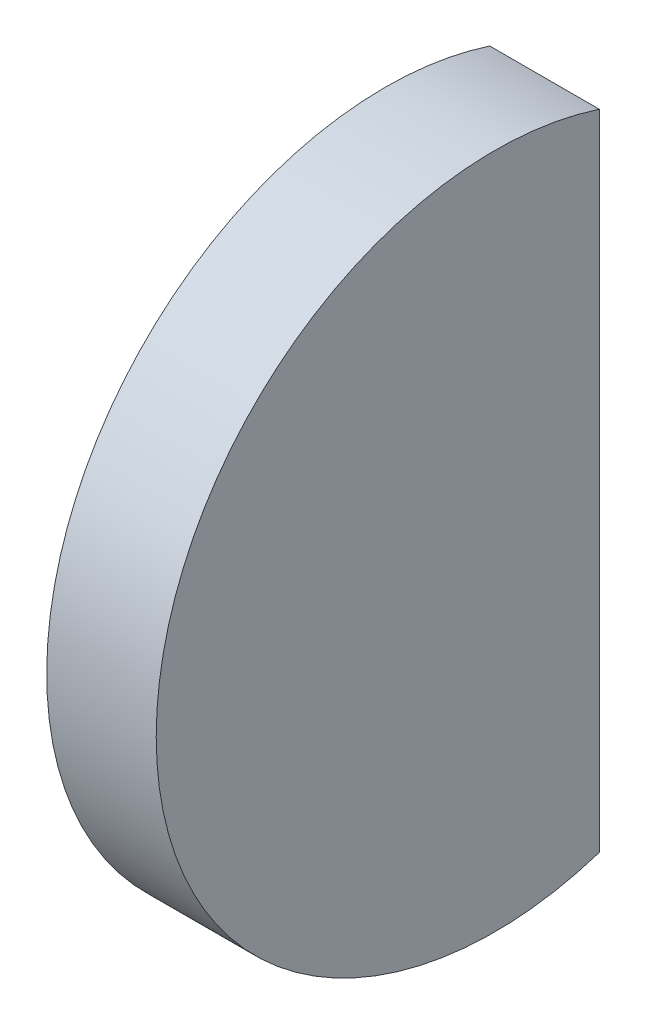
from build123d import *

# Parameters (mm, degrees)
CUT_EXTRUDE_1_DEPTH = 6.5


with BuildPart() as part:
    # Эскиз1 → Повернуть1 (revolve)
    with BuildSketch(Plane.XY):
        with BuildLine():
            Line((1.941000017, 11), (5.5, 11))
            Line((5.5, 11), (5.5, 0))
            Line((5.5, 0), (0, 0))
            ThreePointArc((0, 0), (0.488969531, 5.584968242), (1.941000017, 11))
        make_face()
    revolve(axis=Axis((0, 0, 0), (1, 0, 0)))

    # Эскиз2 → Вырез-Вытянуть1 (cut, through all)
    with BuildSketch(Plane(origin=(5.5, 0, 0), x_dir=(0, 0, -1), z_dir=(1, 0, 0))):
        Polygon((3.4, 72.15080955), (3.4, 10.461357464), (3.4, -10.461357464), (3.4, -72.15080955), (126.778904171, -72.15080955), (126.778904171, 72.15080955), align=None)
    extrude(amount=-CUT_EXTRUDE_1_DEPTH, mode=Mode.SUBTRACT)


solid = part.part
